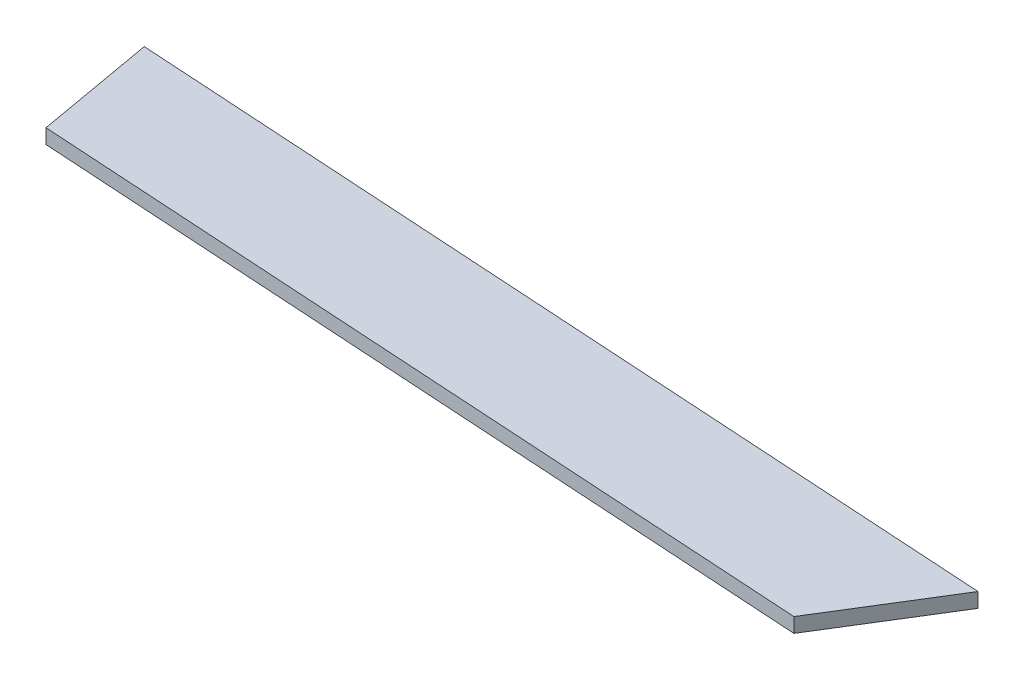
from build123d import *

# Parameters (mm, degrees)
BOSS_EXTRU_1_DEPTH = 2


with BuildPart() as part:
    # Esquisse1 → Boss.-Extru.1 (new body)
    with BuildSketch(Plane(origin=(0, 0, 0), x_dir=(1, 0, 0), z_dir=(0, 1, 0))):
        Polygon((109.181194573, -6.763482991), (118.815081062, 8.811380073), (-2.896915031, 16.351112705), (0, 0), align=None)
    extrude(amount=BOSS_EXTRU_1_DEPTH)


solid = part.part
